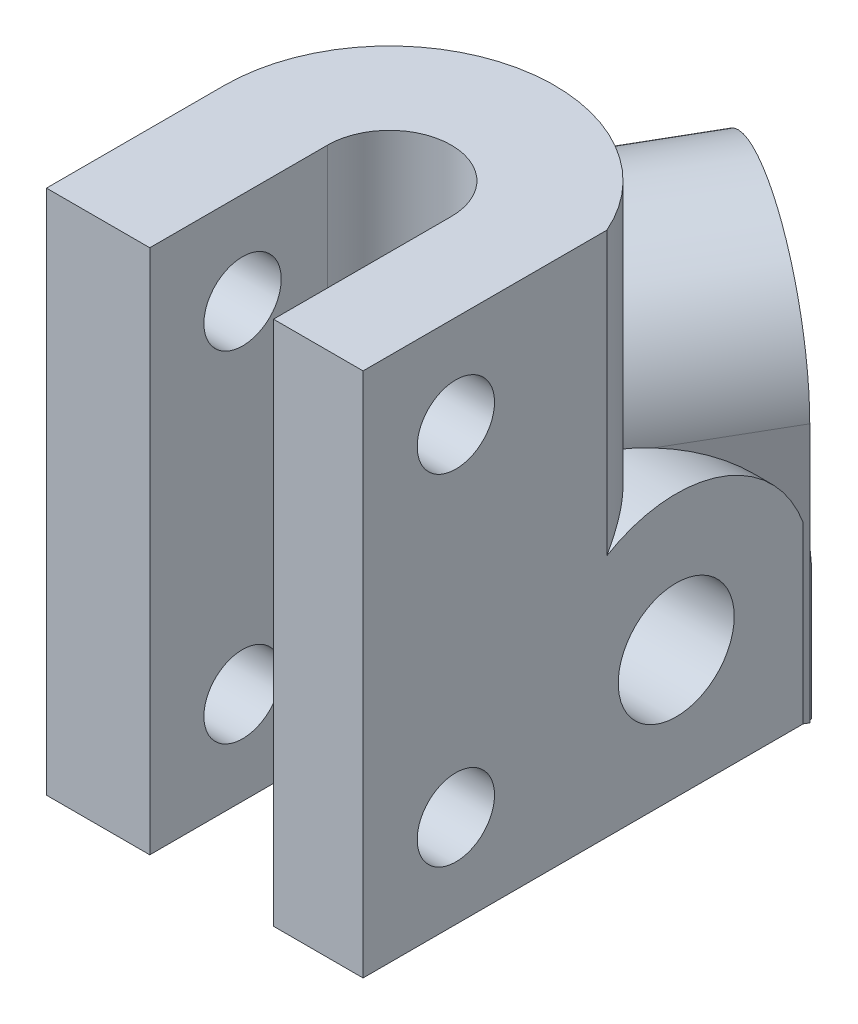
from build123d import *

# Parameters (mm, degrees)
SKETCH1_R               = 3.75
BOSS_EXTRUDE1_DEPTH     = 30
SKETCH2_R               = 3.75
BOSS_EXTRUDE2_DEPTH     = 30
CUT_EXTRUDE1_DEPTH      = 26.5000001
SKETCH4_W               = 5.792740578
SKETCH4_H               = 11.5
BOSS_EXTRUDE3_DEPTH     = 10
BOSS_EXTRUDE4_DEPTH     = 10
BOSS_EXTRUDE5_DEPTH     = 34
SKETCH5_R               = 2.5
CUT_EXTRUDE2_DEPTH      = 31.0000001
SKETCH7_R               = 3.75
CUT_EXTRUDE3_DEPTH      = 31.155444666
SKETCH8_R               = 3.75
CUT_EXTRUDE4_DEPTH      = 27.5
CUT_EXTRUDE4_DEPTH_BACK = 38.57772242


with BuildPart() as part:
    # Sketch1 → Boss-Extrude1 (new body)
    with BuildSketch(Plane(origin=(0, 0, 0), x_dir=(0, 0, -1), z_dir=(1, 0, 0))):
        with BuildLine():
            Line((-8.75, 0), (8.75, 0))
            Line((8.75, 0), (8.75, 8.25))
            ThreePointArc((8.75, 8.25), (0, 17), (-8.75, 8.25))
            Line((-8.75, 8.25), (-8.75, 0))
        make_face()
        with Locations((0, 8.25)):
            Circle(SKETCH1_R, mode=Mode.SUBTRACT)
    extrude(amount=BOSS_EXTRUDE1_DEPTH)

    # Sketch2 → Boss-Extrude2 (add)
    with BuildSketch(Plane(origin=(-3.788861142, 0, 6.5625), x_dir=(-0.866025404, 0, -0.5), z_dir=(0.5, 0, -0.866025404))):
        with BuildLine():
            Line((-4.375, 0), (-4.375, 16.75))
            ThreePointArc((-4.375, 16.75), (-13.125, 25.5), (-21.875, 16.75))
            Line((-21.875, 16.75), (-21.875, 0))
            Line((-21.875, 0), (-4.375, 0))
        make_face()
        with Locations((-13.125, 16.75)):
            Circle(SKETCH2_R, mode=Mode.SUBTRACT)
    extrude(amount=BOSS_EXTRUDE2_DEPTH)

    # Sketch3 → Cut-Extrude1 (cut, through all)
    with BuildSketch(Plane.XZ):
        with BuildLine():
            Line((24.207259422, 8.75), (24.207259422, 15.67820323))
            Line((24.207259422, 15.67820323), (16.207259422, 15.67820323))
            Line((16.207259422, 15.67820323), (16.207259422, 8.75))
            ThreePointArc((16.207259422, 8.75), (20.207259422, 4.75), (24.207259422, 8.75))
        make_face()
    extrude(amount=-CUT_EXTRUDE1_DEPTH, mode=Mode.SUBTRACT)

    # Sketch4 → Boss-Extrude3 (add)
    with BuildSketch(Plane.XZ):
        with Locations((27.103629711, 14.5)):
            Rectangle(SKETCH4_W, SKETCH4_H)
    extrude(amount=-BOSS_EXTRUDE3_DEPTH)

    # Sketch6 → Boss-Extrude4 (add)
    with BuildSketch(Plane.XZ):
        Polygon((16.207259422, 15.67820323), (16.207259422, 20.25), (9.526279442, 20.25), (9.526279442, 14.25), align=None)
    extrude(amount=-BOSS_EXTRUDE4_DEPTH)

    # Sketch9 → Boss-Extrude5 (add)
    with BuildSketch(Plane.XZ):
        with BuildLine():
            Line((16.207259422, 20.25), (9.526279442, 20.25))
            Line((9.526279442, 20.25), (9.526279442, 14.25))
            Line((9.526279442, 14.25), (9.526279442, 8.75))
            ThreePointArc((9.526279442, 8.75), (18.029270984, -1.706562518), (30, 4.485546307))
            Line((30, 4.485546307), (30, 20.25))
            Line((30, 20.25), (24.207259422, 20.25))
            Line((24.207259422, 20.25), (24.207259422, 8.75))
            ThreePointArc((24.207259422, 8.75), (20.207259422, 4.75), (16.207259422, 8.75))
            Line((16.207259422, 8.75), (16.207259422, 20.25))
        make_face()
    extrude(amount=-BOSS_EXTRUDE5_DEPTH)

    # Sketch5 → Cut-Extrude2 (cut, through all)
    with BuildSketch(Plane(origin=(30, 0, 0), x_dir=(0, 0, -1), z_dir=(1, 0, 0))):
        with Locations(Location((-14.25, 6, 0), (0, 0, 90))):  # turned: the seam where the file's is
            Circle(SKETCH5_R)
        with Locations(Location((-14.25, 28, 0), (0, 0, 180))):  # turned: the seam where the file's is
            Circle(SKETCH5_R)
    extrude(amount=-CUT_EXTRUDE2_DEPTH, mode=Mode.SUBTRACT)

    # Sketch7 → Cut-Extrude3 (cut, through all)
    with BuildSketch(Plane.ZY):
        with Locations(Location((0, 8.25, 0), (0, 0, 180))):  # turned: the seam where the file's is
            Circle(SKETCH7_R)
    extrude(amount=-CUT_EXTRUDE3_DEPTH, mode=Mode.SUBTRACT)

    # Sketch8 → Cut-Extrude4 (cut, two sides)
    with BuildSketch(Plane(origin=(-3.788861142, 0, 6.5625), x_dir=(0.866025404, 0, 0.5), z_dir=(-0.5, 0, 0.866025404))) as cut_extrude4_sk:
        with Locations(Location((13.125, 16.75, 0), (0, 0, 53.130102354))):  # turned: the seam where the file's is
            Circle(SKETCH8_R)
    extrude(amount=CUT_EXTRUDE4_DEPTH, mode=Mode.SUBTRACT)
    extrude(cut_extrude4_sk.sketch, amount=-CUT_EXTRUDE4_DEPTH_BACK, mode=Mode.SUBTRACT)


solid = part.part
